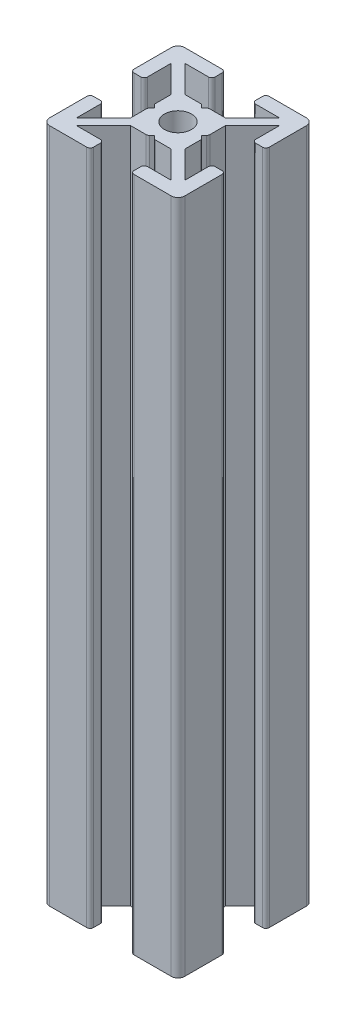
from build123d import *

# Parameters (mm, degrees)
SKETCH1_R           = 2
BOSS_EXTRUDE1_DEPTH = 100
FILLET1_R           = 1
FILLET2_R           = 0.5
FILLET4_R           = 0.5


with BuildPart() as part:
    # Sketch1 → Boss-Extrude1 (new body)
    with BuildSketch(Plane(origin=(0, 0, 0), x_dir=(1, 0, 0), z_dir=(0, 1, 0))):
        Polygon((7, 18), (7, 20), (0, 20), (0, 13), (2, 13), (2, 17), (6, 13), (6, 10.5), (6.5, 10), (6, 9.5), (6, 7), (2, 3), (2, 7), (0, 7), (0, 0), (7, 0), (7, 2), (3, 2), (7, 6), (9.5, 6), (10, 6.5), (10.5, 6), (13, 6), (17, 2), (13, 2), (13, 0), (20, 0), (20, 7), (18, 7), (18, 3), (14, 7), (14, 9.5), (13.5, 10), (14, 10.5), (14, 13), (18, 17), (18, 13), (20, 13), (20, 20), (13, 20), (13, 18), (17, 18), (13, 14), (10.5, 14), (10, 13.5), (9.5, 14), (7, 14), (3, 18), align=None)
        with Locations((10, 10)):
            Circle(SKETCH1_R, mode=Mode.SUBTRACT)
    extrude(amount=BOSS_EXTRUDE1_DEPTH)

    # Fillet1
    fillet1_edges = [part.edges().sort_by_distance(p)[0] for p in [
        (0, 50, -20),
        (20, 50, -20),
        (20, 50, 0),
        (0, 50, 0),
    ]]
    fillet(fillet1_edges, radius=FILLET1_R)

    # Fillet2
    fillet2_edges = [part.edges().sort_by_distance(p)[0] for p in [
        (2, 50, -13),
        (0, 50, -13),
        (7, 50, -20),
        (7, 50, -18),
        (13, 50, -18),
        (13, 50, -20),
        (20, 50, -13),
        (18, 50, -13),
        (18, 50, -7),
        (20, 50, -7),
        (13, 50, 0),
        (13, 50, -2),
        (7, 50, -2),
        (7, 50, 0),
        (0, 50, -7),
        (2, 50, -7),
    ]]
    fillet(fillet2_edges, radius=FILLET2_R)

    # Fillet4
    fillet4_edges = [part.edges().sort_by_distance(p)[0] for p in [
        (9.5, 50, -14),
        (10.5, 50, -14),
        (14, 50, -10.5),
        (14, 50, -9.5),
        (10.5, 50, -6),
        (9.5, 50, -6),
        (6, 50, -9.5),
        (6, 50, -10.5),
    ]]
    fillet(fillet4_edges, radius=FILLET4_R)


solid = part.part
